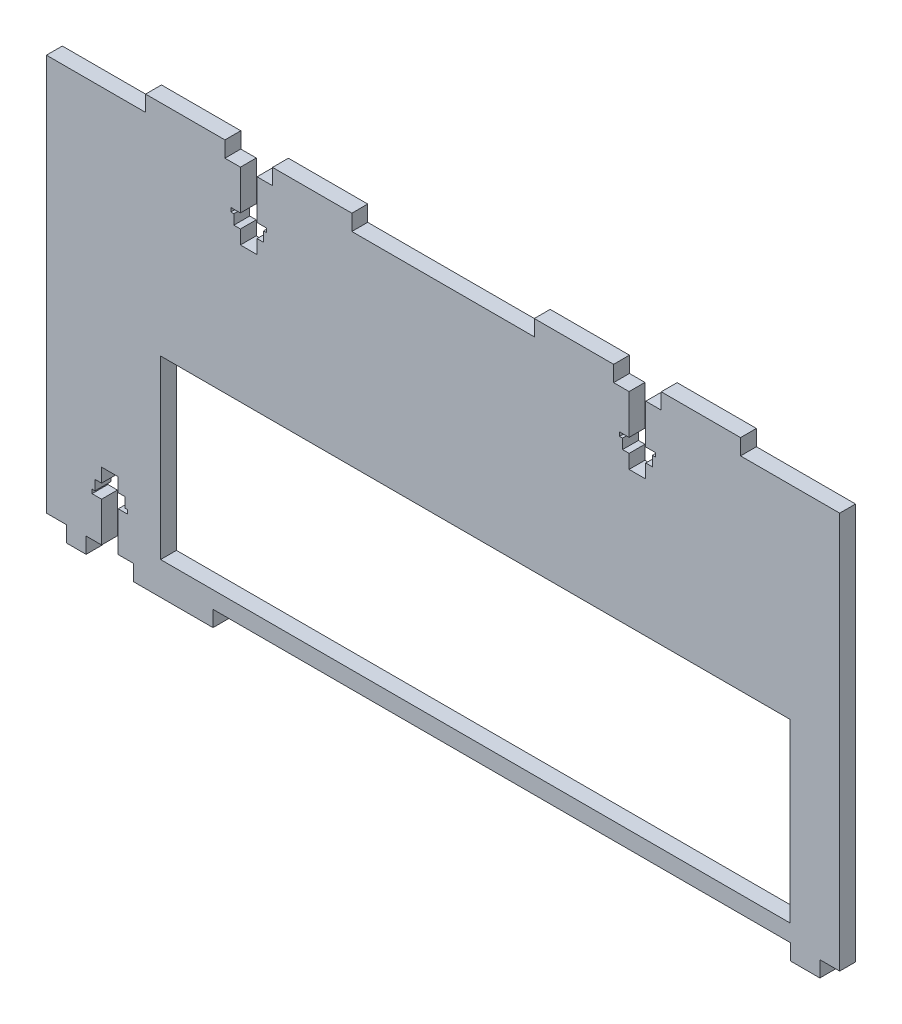
from build123d import *

# Parameters (mm, degrees)
BOSS_EXTRUDE1_DEPTH = 4
SKETCH2_W           = 158.75
SKETCH2_H           = 44.45
CUT_EXTRUDE1_DEPTH  = 6
CUT_EXTRUDE2_DEPTH  = 10
SKETCH4_W           = 5
SKETCH4_H           = 4
CUT_EXTRUDE3_DEPTH  = 10


with BuildPart() as part:
    # Sketch1 → Boss-Extrude1 (new body)
    with BuildSketch(Plane.XY):
        Polygon((-55, 50), (-43, 50), (-43, 54), (-23, 54), (-23, 50), (23, 50), (23, 54), (43, 54), (43, 50), (55, 50), (55, 54), (75, 54), (75, 50), (100, 50), (100, -50), (95, -50), (95, -54), (87.6, -54), (87.6, -50), (-58, -50), (-58, -54), (-78, -54), (-78, -50), (-90, -50), (-90, -54), (-100, -54), (-100, -50), (-100, 50), (-75, 50), (-75, 54), (-55, 54), align=None)
    extrude(amount=BOSS_EXTRUDE1_DEPTH)

    # Sketch2 → Cut-Extrude1 (cut)
    with BuildSketch(Plane(origin=(0, 0, 0), x_dir=(-1, 0, 0), z_dir=(0, 0, -1))):
        with Locations((-8.155, -23.515)):
            Rectangle(SKETCH2_W, SKETCH2_H)
    extrude(amount=-CUT_EXTRUDE1_DEPTH, mode=Mode.SUBTRACT)

    # Sketch3 → Cut-Extrude2 (cut)
    with BuildSketch(Plane(origin=(0, 0, 0), x_dir=(-1, 0, 0), z_dir=(0, 0, -1))):
        Polygon((-46.9, 50), (-51.1, 50), (-51.1, 40), (-53.5, 40), (-53.5, 39), (-52.75, 39), (-52.75, 36.5), (-51.1, 36.5), (-51.1, 33), (-46.9, 33), (-46.9, 36.5), (-45.25, 36.5), (-45.25, 39), (-44.5, 39), (-44.5, 40), (-46.9, 40), align=None)
        Polygon((51.1, 40), (51.1, 50), (46.9, 50), (46.9, 40), (44.5, 40), (44.5, 39), (45.25, 39), (45.25, 36.5), (46.9, 36.5), (46.9, 33), (51.1, 33), (51.1, 36.5), (52.75, 36.5), (52.75, 39), (53.5, 39), (53.5, 40), align=None)
        Polygon((81.9, -40), (81.9, -50), (86.1, -50), (86.1, -40), (88.5, -40), (88.5, -39), (87.75, -39), (87.75, -36.5), (86.1, -36.5), (86.1, -33), (81.9, -33), (81.9, -36.5), (80.25, -36.5), (80.25, -39), (79.5, -39), (79.5, -40), align=None)
    extrude(amount=-CUT_EXTRUDE2_DEPTH, mode=Mode.SUBTRACT)

    # Sketch4 → Cut-Extrude3 (cut)
    with BuildSketch(Plane(origin=(0, 0, 0), x_dir=(-1, 0, 0), z_dir=(0, 0, -1))):
        with Locations((97.5, -52)):
            Rectangle(SKETCH4_W, SKETCH4_H)
    extrude(amount=-CUT_EXTRUDE3_DEPTH, mode=Mode.SUBTRACT)


solid = part.part
